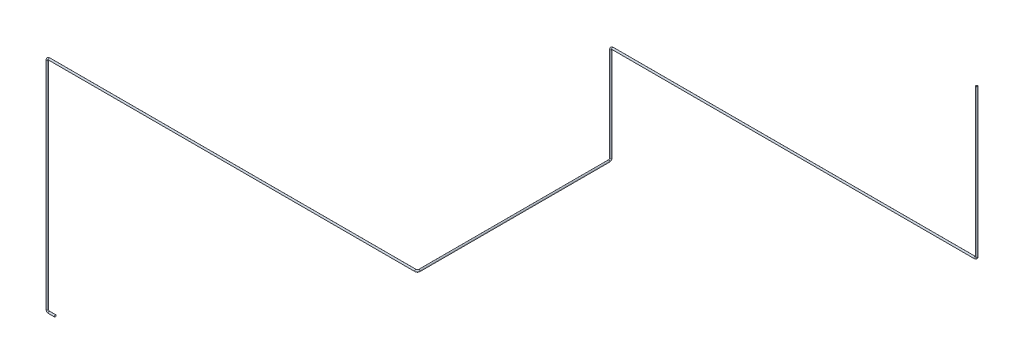
from build123d import *

# Parameters (mm, degrees)
SWEEP_THIN1_PROFILE_R   = 15
SWEEP_THIN1_PROFILE_R_2 = 14


with BuildPart() as part:
    # Sweep-Thin1: sweep along a curve in space
    with BuildLine() as sweep_thin1_path:
        Line((-21783.311263711, -6172.599431658, 38950.249256714), (-21783.311263711, -8593.920823817, 38950.249256714))
        ThreePointArc((-21813.311263711, -8623.920823817, 38950.249256714), (-21792.098060276, -8615.134027253, 38950.249256714), (-21783.311263711, -8593.920823817, 38950.249256714))
        Line((-21813.311263711, -8623.920823817, 38950.249256714), (-27753.52983979, -8623.920823817, 38950.249256714))
        ThreePointArc((-27783.52983979, -8653.920823817, 38950.249256714), (-27774.743043225, -8632.707620381, 38950.249256714), (-27753.52983979, -8623.920823817, 38950.249256714))
        Line((-27783.52983979, -8653.920823817, 38950.249256714), (-27783.52983979, -10192.437923061, 38950.249256714))
        ThreePointArc((-27783.52983979, -10222.437923061, 38980.249256714), (-27783.52983979, -10213.651126497, 38959.036053279), (-27783.52983979, -10192.437923061, 38950.249256714))
        Line((-27783.52983979, -10222.437923061, 38980.249256714), (-27783.52983979, -10222.437923061, 42091.700196057))
        ThreePointArc((-27813.52983979, -10222.437923061, 42121.700196057), (-27792.316636354, -10222.437923061, 42112.913399492), (-27783.52983979, -10222.437923061, 42091.700196057))
        Line((-27813.52983979, -10222.437923061, 42121.700196057), (-33823.264850624, -10222.437923061, 42121.700196057))
        ThreePointArc((-33853.264850624, -10252.437923061, 42121.700196057), (-33844.47805406, -10231.224719626, 42121.700196057), (-33823.264850624, -10222.437923061, 42121.700196057))
        Line((-33853.264850624, -10252.437923061, 42121.700196057), (-33853.264850624, -13792.013633934, 42121.700196057))
        ThreePointArc((-33823.264850624, -13822.013633934, 42121.700196057), (-33844.47805406, -13813.22683737, 42121.700196057), (-33853.264850624, -13792.013633934, 42121.700196057))
        Line((-33823.264850624, -13822.013633934, 42121.700196057), (-33723.264850624, -13822.013633934, 42121.700196057))
    # Sweep-Thin1 profile (on start of the path) → Sweep-Thin1 (sweep)
    with BuildSketch(Plane(origin=(-21783.311263711, -6172.599431658, 38950.249256714), x_dir=(0, 0, -1), z_dir=(0, -1, 0))):
        Circle(SWEEP_THIN1_PROFILE_R)
        Circle(SWEEP_THIN1_PROFILE_R_2, mode=Mode.SUBTRACT)
    sweep(path=sweep_thin1_path.line)


solid = part.part
